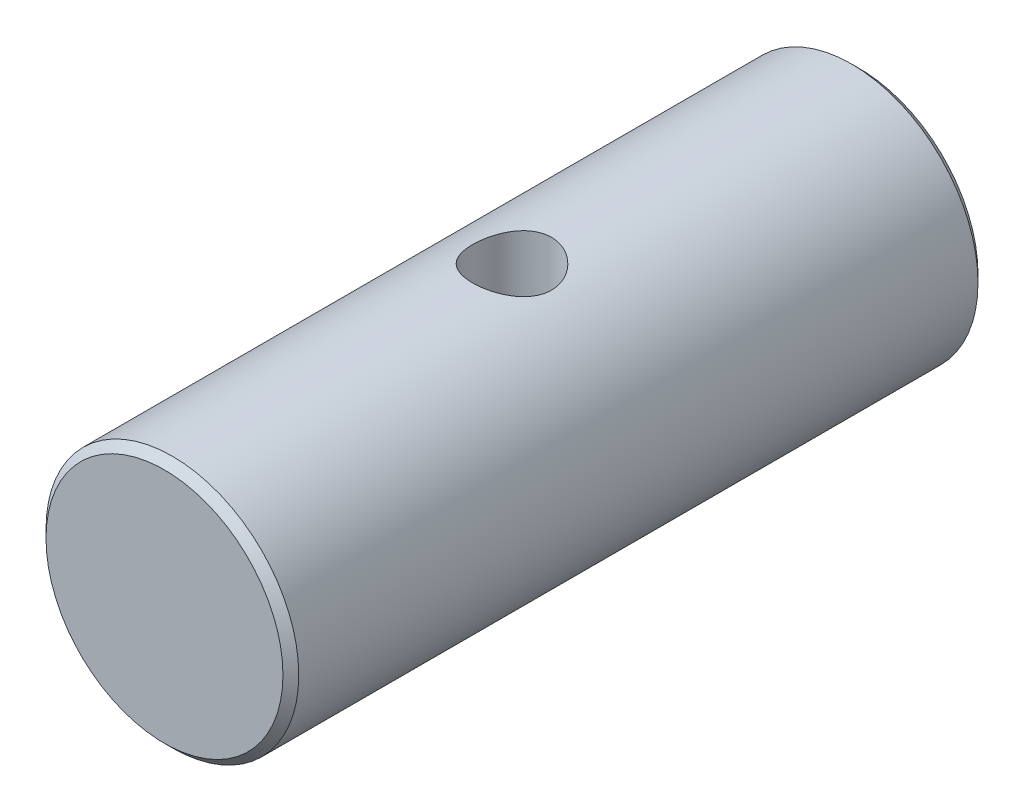
from build123d import *

# Parameters (mm, degrees)
SKETCH1_R               = 8
BOSS_EXTRUDE1_DEPTH     = 44
SKETCH2_R               = 2.5
CUT_EXTRUDE1_DEPTH      = 9
CUT_EXTRUDE1_DEPTH_BACK = 9
CHAMFER1_SIZE           = 0.5


with BuildPart() as part:
    # Sketch1 → Boss-Extrude1 (new body)
    with BuildSketch(Plane.XY):
        Circle(SKETCH1_R)
    extrude(amount=BOSS_EXTRUDE1_DEPTH)

    # Sketch2 → Cut-Extrude1 (cut, two sides)
    with BuildSketch(Plane(origin=(0, 0, 0), x_dir=(1, 0, 0), z_dir=(0, 1, 0))) as cut_extrude1_sk:
        with Locations((0, -22)):
            Circle(SKETCH2_R)
    extrude(amount=CUT_EXTRUDE1_DEPTH, mode=Mode.SUBTRACT)
    extrude(cut_extrude1_sk.sketch, amount=-CUT_EXTRUDE1_DEPTH_BACK, mode=Mode.SUBTRACT)

    # Chamfer1
    chamfer1_edges = [part.edges().sort_by_distance(p)[0] for p in [
        (-8, 0, 0),
        (-8, 0, 44),
    ]]
    chamfer(chamfer1_edges, length=CHAMFER1_SIZE)


solid = part.part
